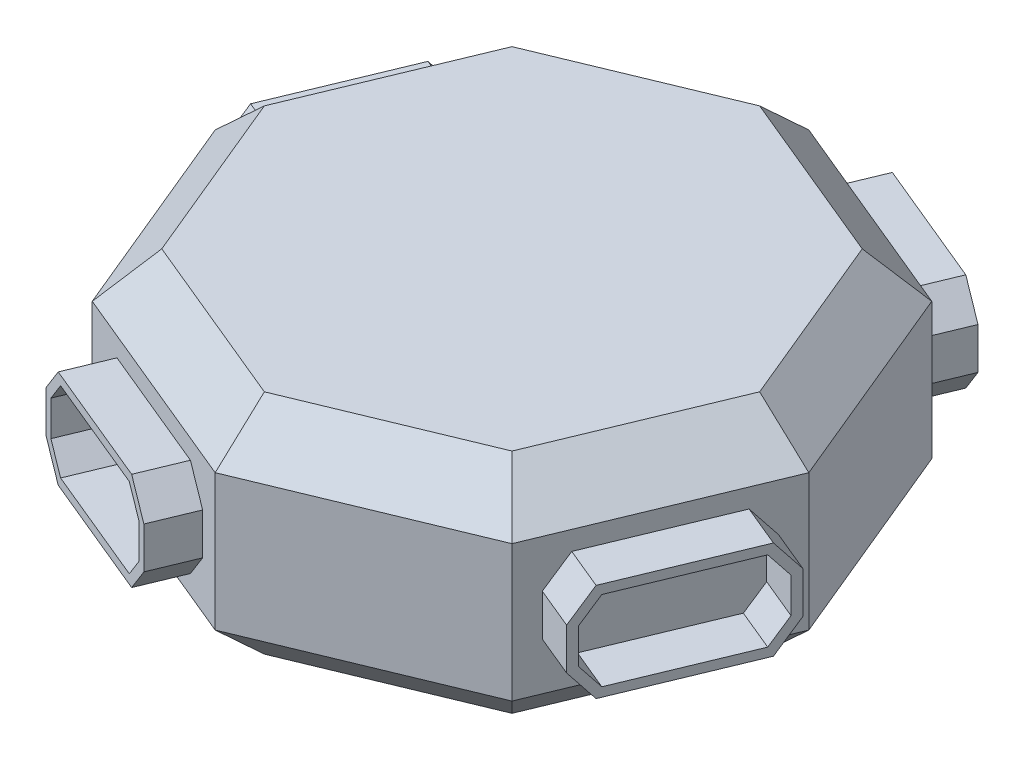
from build123d import *

# Parameters (mm, degrees)
EXTRUDE_1_DEPTH          = 25
CUT_EXTRUDE_1_DEPTH      = 153.008558041
PATTERN_CIRCULAR_1_COUNT = 8
EXTRUDE_1_2_DEPTH        = 9.9
PATTERN_CIRCULAR_2_COUNT = 4


with BuildPart() as part:
    # 草图1 → Extrude 1 (new, symmetric)
    with BuildSketch(Plane(origin=(0, 0, 0), x_dir=(1, 0, 0), z_dir=(0, 1, 0))):
        Polygon((0, -65.328148244), (46.193976626, -46.193976626), (65.328148244, 0), (46.193976626, 46.193976626), (0, 65.328148244), (-46.193976626, 46.193976626), (-65.328148244, 0), (-46.193976626, -46.193976626), align=None)
    extrude(amount=EXTRUDE_1_DEPTH, both=True)

    # 草图2 → 切除-拉伸1 (cut, through all)
    with BuildSketch(Plane(origin=(55.761062435, 0, 23.096988313), x_dir=(0.38268343236508157, 0, -0.9238795325112902), z_dir=(0.9238795325112902, 0, 0.38268343236508157))):
        Polygon((-60.355339059, 25), (-60.355339059, 15), (-50.355339059, 25), align=None)
        Polygon((-60.355339059, -25), (-60.355339059, -15), (-50.355339059, -25), align=None)
    cut_extrude_1 = extrude(amount=-CUT_EXTRUDE_1_DEPTH, mode=Mode.SUBTRACT)

    # 阵列(圆周)1: 切除-拉伸1 ×8 about axis
    pattern_circular_1_axis = Axis((0, -27.5, 0), (0, 1, 0))
    for i in range(1, PATTERN_CIRCULAR_1_COUNT):
        add(cut_extrude_1.rotate(pattern_circular_1_axis, i * 360 / PATTERN_CIRCULAR_1_COUNT), mode=Mode.SUBTRACT)

    # 草图3 → Extrude 1 2 (add)
    with BuildSketch(Plane(origin=(-55.761062435, 0, -23.096988313), x_dir=(-0.3826834323650816, 0, 0.9238795325112902), z_dir=(-0.9238795325112902, 0, -0.3826834323650816))):
        Polygon((19.9, 4.565036261), (14.936812049, 10.795), (-14.936812049, 10.795), (-19.9, 4.565036261), (-19.9, -4.565036261), (-14.936812049, -10.795), (14.936812049, -10.795), (19.9, -4.565036261), align=None)
        Polygon((17.9, 3.865761475), (13.973053026, 8.795), (-13.973053026, 8.795), (-17.9, 3.865761475), (-17.9, -3.865761475), (-13.973053026, -8.795), (13.973053026, -8.795), (17.9, -3.865761475), align=None, mode=Mode.SUBTRACT)
    extrude_1_2 = extrude(amount=EXTRUDE_1_2_DEPTH)

    # 阵列(圆周)2: Extrude 1 2 ×4 about axis
    pattern_circular_2_axis = Axis((0, -27.5, 0), (0, 1, 0))
    for i in range(1, PATTERN_CIRCULAR_2_COUNT):
        add(extrude_1_2.rotate(pattern_circular_2_axis, i * 360 / PATTERN_CIRCULAR_2_COUNT))


solid = part.part
